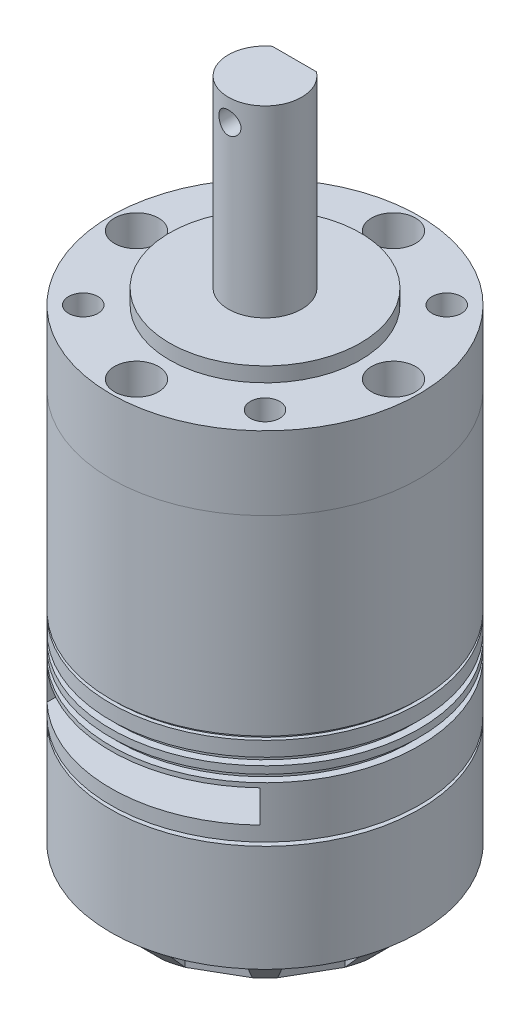
from build123d import *

# Parameters (mm, degrees)
SKETCH_1_R             = 21
EXTRUDE_1_DEPTH        = 31
CHAMFER_1_SIZE         = 3.5
CUT_EXTRUDE_1_DEPTH    = 3.5
SKETCH_3_R             = 21
EXTRUDE_2_DEPTH        = 26
SKETCH_4_R             = 21
EXTRUDE_3_DEPTH        = 10
SKETCH_5_R             = 13
EXTRUDE_4_DEPTH        = 2
SKETCH_6_R             = 5
EXTRUDE_5_DEPTH        = 25
SKETCH_7_W             = 10.482842212
SKETCH_7_H             = 3.27064677
CUT_EXTRUDE_D_DEPTH    = 20
SKETCH_8_R             = 21
SKETCH_8_R_2           = 20.5
CUT_EXTRUDE_3_DEPTH    = 0.5
SKETCH_9_R             = 21
SKETCH_9_R_2           = 20
CUT_EXTRUDE_4_DEPTH    = 1
SKETCH_10_R            = 21
SKETCH_10_R_2          = 20
CUT_EXTRUDE_5_DEPTH    = 1
SKETCH_11_R            = 21
SKETCH_11_R_2          = 20
CUT_EXTRUDE_6_DEPTH    = 0.5
SKETCH_12_W            = 29
SKETCH_12_H            = 13.007110616
CUT_EXTRUDE_7_DEPTH    = 4.4
SKETCH_13_W            = 29
SKETCH_13_H            = 4.4
CUT_EXTRUDE_8_DEPTH    = 5
SKETCH_14_R            = 3
SKETCH_14_R_2          = 2
CUT_EXTRUDE_2347_DEPTH = 8
SKETCH_15_R            = 3.5
EXTRUDE_6_DEPTH        = 5
SKETCH_16_R            = 1.5
CUT_EXTRUDE_10_DEPTH   = 5
SKETCH_17_R            = 1.5
CUT_EXTRUDE_11_DEPTH   = 10


with BuildPart() as part:
    # 草图1 → 凸台-拉伸1 (new body)
    with BuildSketch(Plane(origin=(0, 0, 0), x_dir=(1, 0, 0), z_dir=(0, 1, 0))):
        Circle(SKETCH_1_R)
    extrude(amount=EXTRUDE_1_DEPTH)

    # 倒角1
    chamfer_1_edges = [part.edges().sort_by_distance(p)[0] for p in [
        (-21, 0, 0),
    ]]
    chamfer(chamfer_1_edges, length=CHAMFER_1_SIZE)

    # 草图2 → 切除-拉伸1 (cut)
    with BuildSketch(Plane.XZ):
        Polygon((3.35, -17.176364575), (-3.35, -17.176364575), (-3.85, -20.644066944), (-3.85, -22.494899201), (3.85, -22.494899201), (3.85, -20.644066944), align=None)
        Polygon((-6.987835668, -19.803286411), (-5.686997185, -16.550168066), (-11.48936739, -13.200168066), (-13.656231277, -15.953286411), (-14.581647405, -17.556154163), (-7.913251796, -21.406154163), align=None)
        Polygon((-15.953286411, -13.656231277), (-13.200168066, -11.48936739), (-16.550168066, -5.686997185), (-19.803286411, -6.987835668), (-21.406154163, -7.913251796), (-17.556154163, -14.581647405), align=None)
        Polygon((-20.644066944, -3.85), (-17.176364575, -3.35), (-17.176364575, 3.35), (-20.644066944, 3.85), (-22.494899201, 3.85), (-22.494899201, -3.85), align=None)
        Polygon((-19.803286411, 6.987835668), (-16.550168066, 5.686997185), (-13.200168066, 11.48936739), (-15.953286411, 13.656231277), (-17.556154163, 14.581647405), (-21.406154163, 7.913251796), align=None)
        Polygon((-13.656231277, 15.953286411), (-11.48936739, 13.200168066), (-5.686997185, 16.550168066), (-6.987835668, 19.803286411), (-7.913251796, 21.406154163), (-14.581647405, 17.556154163), align=None)
        Polygon((-3.85, 20.644066944), (-3.35, 17.176364575), (3.35, 17.176364575), (3.85, 20.644066944), (3.85, 22.494899201), (-3.85, 22.494899201), align=None)
        Polygon((6.987835668, 19.803286411), (5.686997185, 16.550168066), (11.48936739, 13.200168066), (13.656231277, 15.953286411), (14.581647405, 17.556154163), (7.913251796, 21.406154163), align=None)
        Polygon((15.953286411, 13.656231277), (13.200168066, 11.48936739), (16.550168066, 5.686997185), (19.803286411, 6.987835668), (21.406154163, 7.913251796), (17.556154163, 14.581647405), align=None)
        Polygon((20.644066944, 3.85), (17.176364575, 3.35), (17.176364575, -3.35), (20.644066944, -3.85), (22.494899201, -3.85), (22.494899201, 3.85), align=None)
        Polygon((19.803286411, -6.987835668), (16.550168066, -5.686997185), (13.200168066, -11.48936739), (15.953286411, -13.656231277), (17.556154163, -14.581647405), (21.406154163, -7.913251796), align=None)
        Polygon((13.656231277, -15.953286411), (11.48936739, -13.200168066), (5.686997185, -16.550168066), (6.987835668, -19.803286411), (7.913251796, -21.406154163), (14.581647405, -17.556154163), align=None)
    extrude(amount=-CUT_EXTRUDE_1_DEPTH, mode=Mode.SUBTRACT)

    # 草图8 → 切除-拉伸3 (cut)
    with BuildSketch(Plane(origin=(0, 31, 0), x_dir=(-1, 0, 0), z_dir=(0, -1, 0))):
        Circle(SKETCH_8_R)
        Circle(SKETCH_8_R_2, mode=Mode.SUBTRACT)
    extrude(amount=CUT_EXTRUDE_3_DEPTH, mode=Mode.SUBTRACT)

    # 草图9 → 切除-拉伸4 (cut)
    with BuildSketch(Plane(origin=(0, 26.5, 0), x_dir=(-1, 0, 0), z_dir=(0, -1, 0))):
        Circle(SKETCH_9_R)
        Circle(SKETCH_9_R_2, mode=Mode.SUBTRACT)
    extrude(amount=CUT_EXTRUDE_4_DEPTH, mode=Mode.SUBTRACT)

    # 草图10 → 切除-拉伸5 (cut)
    with BuildSketch(Plane(origin=(0, 27.5, 0), x_dir=(-1, 0, 0), z_dir=(0, -1, 0))):
        Circle(SKETCH_10_R)
        Circle(SKETCH_10_R_2, mode=Mode.SUBTRACT)
    extrude(amount=-CUT_EXTRUDE_5_DEPTH, mode=Mode.SUBTRACT)

    # 草图11 → 切除-拉伸6 (cut)
    with BuildSketch(Plane(origin=(0, 18, 0), x_dir=(-1, 0, 0), z_dir=(0, -1, 0))):
        Circle(SKETCH_11_R)
        Circle(SKETCH_11_R_2, mode=Mode.SUBTRACT)
    extrude(amount=-CUT_EXTRUDE_6_DEPTH, mode=Mode.SUBTRACT)

    # 草图12 → 切除-拉伸7 (cut)
    with BuildSketch(Plane(origin=(0, 24.9, 0), x_dir=(1, 0, 0), z_dir=(0, 1, 0))):
        with Locations((0, -21.694012839)):
            Rectangle(SKETCH_12_W, SKETCH_12_H)
    extrude(amount=-CUT_EXTRUDE_7_DEPTH, mode=Mode.SUBTRACT)

    # 草图13 → 切除-拉伸8 (cut)
    with BuildSketch(Plane.XY.offset(15.190457531)):
        with Locations((0, 22.7)):
            Rectangle(SKETCH_13_W, SKETCH_13_H)
    extrude(amount=-CUT_EXTRUDE_8_DEPTH, mode=Mode.SUBTRACT)

    # 草图15 → 凸台-拉伸6 (add)
    with BuildSketch(Plane.XZ):
        Circle(SKETCH_15_R)
    extrude(amount=EXTRUDE_6_DEPTH)

    # 草图16 → 切除-拉伸10 (cut)
    with BuildSketch(Plane.XZ):
        with Locations((-6.75, 0)):
            Circle(SKETCH_16_R)
        with Locations((6.75, 0)):
            Circle(SKETCH_16_R)
    extrude(amount=-CUT_EXTRUDE_10_DEPTH, mode=Mode.SUBTRACT)


with BuildPart() as body_2:
    # 草图3 → 凸台-拉伸2 (new body)
    with BuildSketch(Plane(origin=(0, 31, 0), x_dir=(1, 0, 0), z_dir=(0, 1, 0))):
        Circle(SKETCH_3_R)
    extrude(amount=EXTRUDE_2_DEPTH)


with BuildPart() as body_3:
    # 草图4 → 凸台-拉伸3 (new body)
    with BuildSketch(Plane(origin=(0, 57, 0), x_dir=(1, 0, 0), z_dir=(0, 1, 0))):
        Circle(SKETCH_4_R)
    extrude(amount=EXTRUDE_3_DEPTH)

    # 草图5 → 凸台-拉伸4 (add)
    with BuildSketch(Plane(origin=(0, 67, 0), x_dir=(1, 0, 0), z_dir=(0, 1, 0))):
        Circle(SKETCH_5_R)
    extrude(amount=EXTRUDE_4_DEPTH)

    # 草图6 → 凸台-拉伸5 (add)
    with BuildSketch(Plane(origin=(0, 69, 0), x_dir=(1, 0, 0), z_dir=(0, 1, 0))):
        Circle(SKETCH_6_R)
    extrude(amount=EXTRUDE_5_DEPTH)

    # 草图7 → D形面 (cut)
    with BuildSketch(Plane(origin=(0, 94, 0), x_dir=(1, 0, 0), z_dir=(0, 1, 0))):
        with Locations((-0.041931369, 5.635323385)):
            Rectangle(SKETCH_7_W, SKETCH_7_H)
    extrude(amount=-CUT_EXTRUDE_D_DEPTH, mode=Mode.SUBTRACT)

    # 草图14 → Cut-Extrude 2347 (cut)
    with BuildSketch(Plane(origin=(0, 67, 0), x_dir=(1, 0, 0), z_dir=(0, 1, 0))):
        with Locations((0, 17.5)):
            Circle(SKETCH_14_R)
        with Locations((-17.5, 0)):
            Circle(SKETCH_14_R)
        with Locations((0, -17.5)):
            Circle(SKETCH_14_R)
        with Locations((17.5, 0)):
            Circle(SKETCH_14_R)
        with Locations((12.374368671, 12.374368671)):
            Circle(SKETCH_14_R_2)
        with Locations((12.374368671, -12.374368671)):
            Circle(SKETCH_14_R_2)
        with Locations((-12.374368671, -12.374368671)):
            Circle(SKETCH_14_R_2)
        with Locations((-12.374368671, 12.374368671)):
            Circle(SKETCH_14_R_2)
    extrude(amount=-CUT_EXTRUDE_2347_DEPTH, mode=Mode.SUBTRACT)

    # 草图17 → 切除-拉伸11 (cut)
    with BuildSketch(Plane(origin=(0, 0, -4), x_dir=(-1, 0, 0), z_dir=(0, 0, -1))):
        with Locations((0, 91)):
            Circle(SKETCH_17_R)
    extrude(amount=-CUT_EXTRUDE_11_DEPTH, mode=Mode.SUBTRACT)


solid = Compound([part.part, body_2.part, body_3.part])
